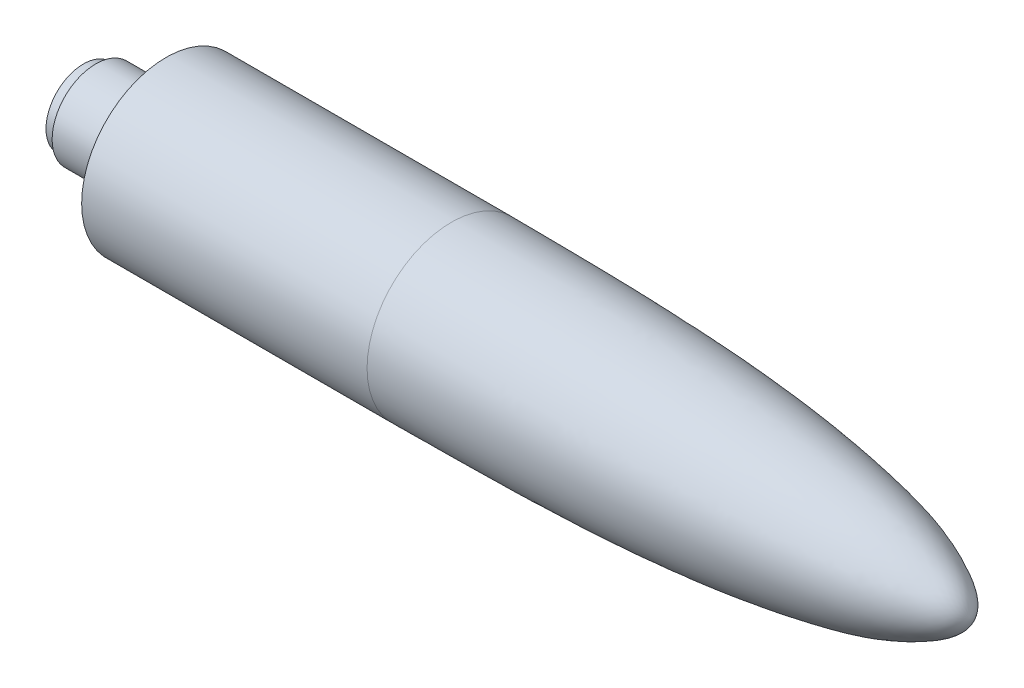
from build123d import *

# Parameters (mm, degrees)
SKETCH2_R           = 2.44
BOSS_EXTRUDE1_DEPTH = 1.5
SKETCH3_R           = 3.1
BOSS_EXTRUDE2_DEPTH = 3.5
SKETCH4_R           = 2.665
BOSS_EXTRUDE3_DEPTH = 0.87


with BuildPart() as part:
    # Sketch1 → Revolve1 (revolve)
    with BuildSketch(Plane(origin=(0, 0, 0), x_dir=(1, 0, 0), z_dir=(0, 1, 0))):
        with BuildLine():
            Line((0, 0), (0, -6))
            Line((0, -6), (20.3, -6))
            add(Edge.make_bspline(
                [(20.3, -6), (29.637498304, -5.936932341), (42.015719343, -5.941972282), (53.939810571, -3.018068917), (57.010038962, -1.04718188), (57.201526924, -0.070177055), (57.2, 0)],
                knots=[0, 0, 0, 0, 0.74911683, 0.92248095, 0.994604009, 1, 1, 1, 1], degree=3))
            Line((57.2, 0), (0, 0))
        make_face()
    revolve(axis=Axis((0, 0, 0), (1, 0, 0)))

    # Sketch2 → Boss-Extrude1 (add)
    with BuildSketch(Plane.ZY):
        Circle(SKETCH2_R)
    extrude(amount=BOSS_EXTRUDE1_DEPTH)

    # Sketch3 → Boss-Extrude2 (add)
    with BuildSketch(Plane.ZY.offset(1.5)):
        Circle(SKETCH3_R)
    extrude(amount=BOSS_EXTRUDE2_DEPTH)

    # Sketch4 → Boss-Extrude3 (add)
    with BuildSketch(Plane.ZY.offset(5)):
        Circle(SKETCH4_R)
    extrude(amount=BOSS_EXTRUDE3_DEPTH)


solid = part.part
